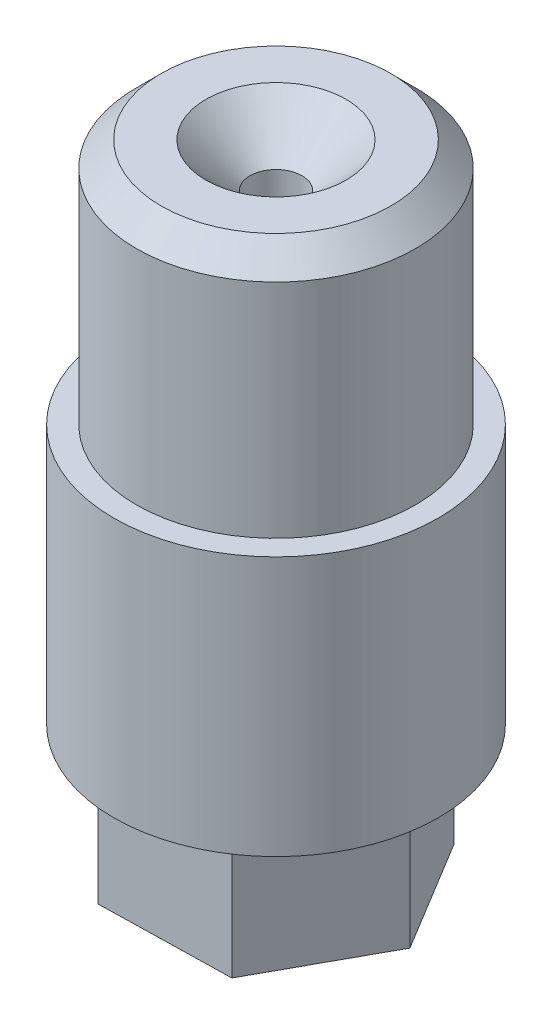
from build123d import *

# Parameters (mm, degrees)
BOSS_EXTRUDE2_DEPTH = 12.7
CHAMFER2_SIZE       = 2.413
SKETCH13_R          = 2.54
CUT_EXTRUDE1_DEPTH  = 63.23


with BuildPart() as part:
    # Sketch1 → Revolve1 (revolve)
    with BuildSketch(Plane.XY):
        Polygon((-15.875, 25.4), (-13.64869, 25.4), (-13.64869, 49.53), (-6.858, 49.53), (0, 42.672), (0, 0), (-15.875, 0), align=None)
    revolve(axis=Axis((0, 110.151211274, 0), (0, -1, 0)))

    # Sketch12 → Boss-Extrude2 (add)
    with BuildSketch(Plane.XZ):
        Polygon((-12.828682674, 0.274060562), (-6.651684746, -10.972934812), (6.176997928, -11.246995373), (12.828682674, -0.274060562), (6.651684746, 10.972934812), (-6.176997928, 11.246995373), align=None)
    extrude(amount=BOSS_EXTRUDE2_DEPTH)

    # Chamfer2
    chamfer2_edges = [part.edges().sort_by_distance(p)[0] for p in [
        (13.64869, 49.53, 0),
    ]]
    chamfer(chamfer2_edges, length=CHAMFER2_SIZE)

    # Sketch13 → Cut-Extrude1 (cut, through all)
    with BuildSketch(Plane.XZ.offset(12.7)):
        Circle(SKETCH13_R)
    extrude(amount=-CUT_EXTRUDE1_DEPTH, mode=Mode.SUBTRACT)


solid = part.part
